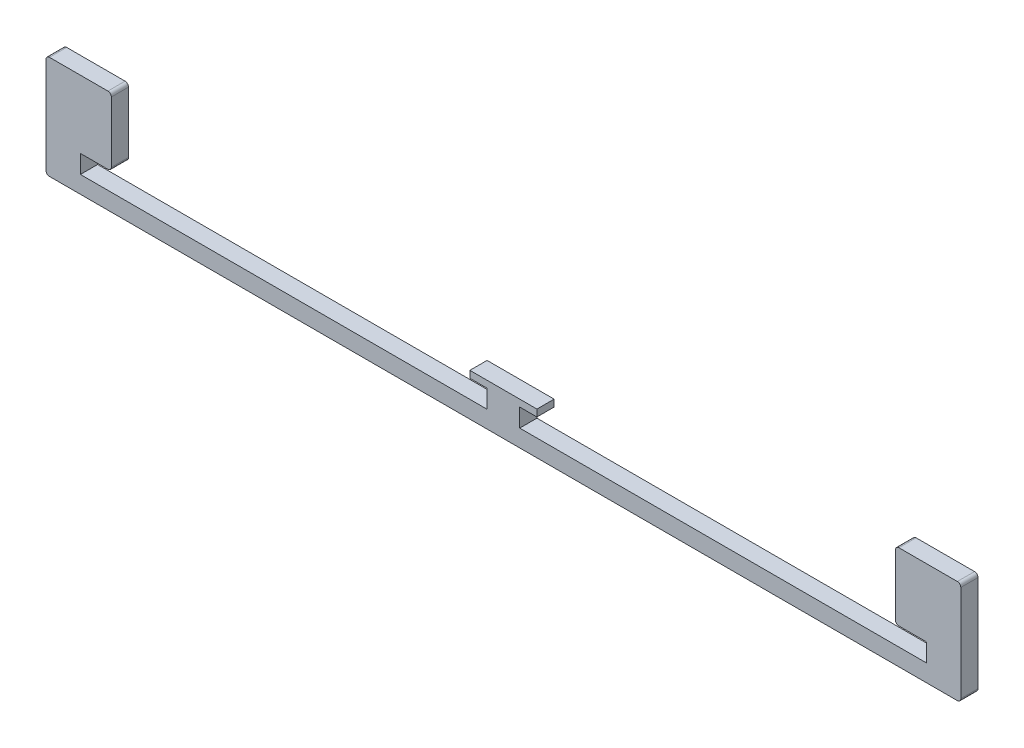
from build123d import *

# Parameters (mm, degrees)
BOSS_EXTRUDE1_DEPTH = 5
FILLET1_R           = 1


with BuildPart() as part:
    # Sketch1 → Boss-Extrude1 (new body)
    with BuildSketch(Plane.XY):
        Polygon((0, 0), (133, 0), (133, 12.3), (123.25, 12.3), (123.25, 10.3), (128.25, 10.3), (128.25, 5), (10, 5), (10, 10.3), (19, 10.3), (19, 30), (0, 30), align=None)
    extrude(amount=BOSS_EXTRUDE1_DEPTH)

    # Mirror1: part across plane


with BuildPart() as part_1:
    add(part.part)
    add(part.part.mirror(Plane(origin=(133, 12.3, 5), x_dir=(0, 0, 1), z_dir=(-1, 0, 0))))

    # Fillet1
    fillet1_edges = [part_1.edges().sort_by_distance(p)[0] for p in [
        (0, 30, 2.5),
        (19, 30, 2.5),
        (19, 10.3, 2.5),
        (0, 0, 2.5),
        (266, 0, 2.5),
        (247, 10.3, 2.5),
        (247, 30, 2.5),
        (266, 30, 2.5),
    ]]
    fillet(fillet1_edges, radius=FILLET1_R)


solid = part_1.part
